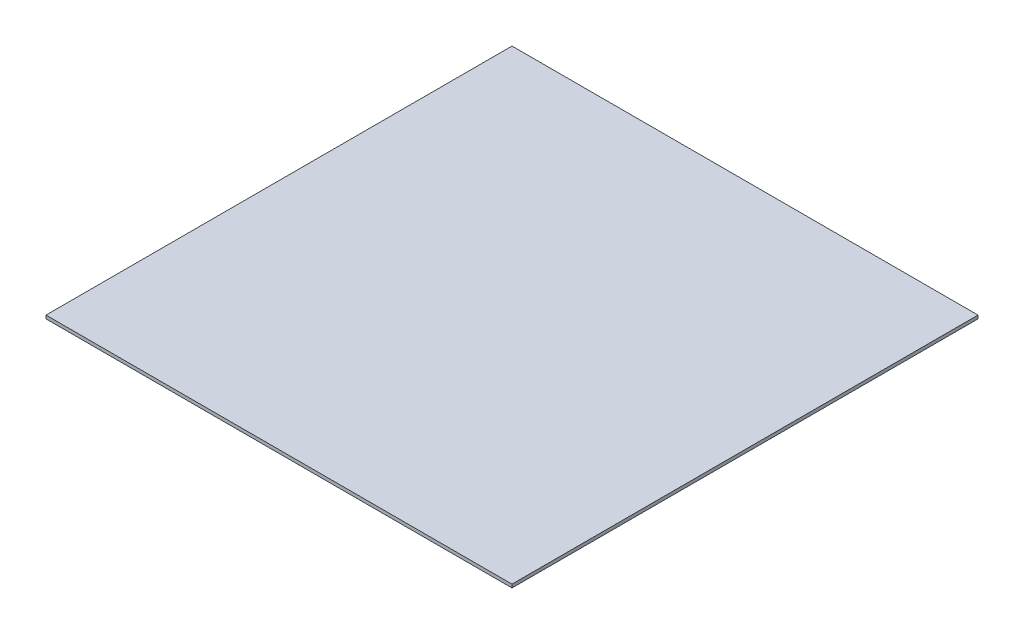
from build123d import *

# Parameters (mm, degrees)
SKETCH1_W           = 107.07
SKETCH1_H           = 107.07
BOSS_EXTRUDE1_DEPTH = 0.762


with BuildPart() as part:
    # Sketch1 → Boss-Extrude1 (new body)
    with BuildSketch(Plane(origin=(0, 0, 0), x_dir=(1, 0, 0), z_dir=(0, 1, 0))):
        with Locations((53.535, 53.535)):
            Rectangle(SKETCH1_W, SKETCH1_H)
    extrude(amount=BOSS_EXTRUDE1_DEPTH)


solid = part.part
